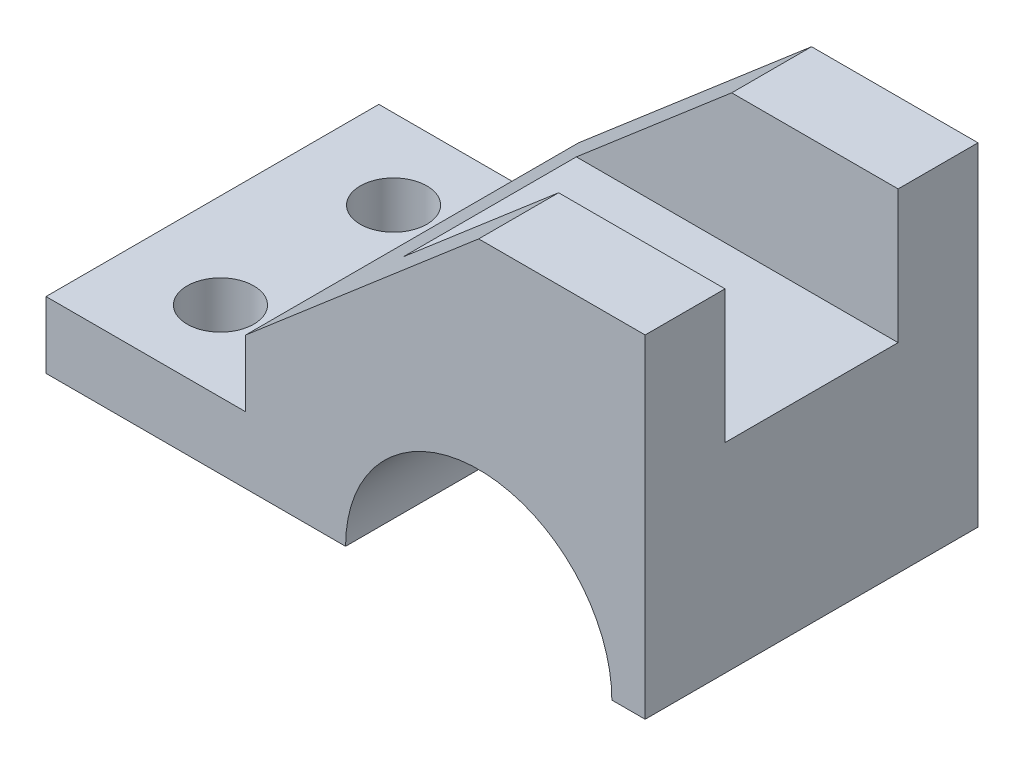
from build123d import *

# Parameters (mm, degrees)
SALIENTE_EXTRUIR2_DEPTH = 50
CROQUIS3_R              = 5
CORTAR_EXTRUIR3_DEPTH   = 10
CROQUIS5_W              = 26
CROQUIS5_H              = 20
CORTAR_EXTRUIR4_DEPTH   = 100


with BuildPart() as part:
    # Croquis1 → Saliente-Extruir2 (new body)
    with BuildSketch(Plane.XY):
        with BuildLine():
            Line((-68.920564692, -21.589574482), (-23.920564692, -21.589574482))
            ThreePointArc((-23.920564692, -21.589574482), (-3.920564692, -1.589574482), (16.079435308, -21.589574482))
            Line((16.079435308, -21.589574482), (21.079435308, -21.589574482))
            Line((21.079435308, -21.589574482), (21.079435308, 28.410425518))
            Line((21.079435308, 28.410425518), (-3.920564692, 28.410425518))
            Line((-3.920564692, 28.410425518), (-38.920564692, -1.589574482))
            Line((-38.920564692, -1.589574482), (-38.920564692, -11.589574482))
            Line((-38.920564692, -11.589574482), (-68.920564692, -11.589574482))
            Line((-68.920564692, -11.589574482), (-68.920564692, -21.589574482))
        make_face()
    extrude(amount=-SALIENTE_EXTRUIR2_DEPTH)

    # Croquis3 → Cortar-Extruir3 (cut)
    with BuildSketch(Plane(origin=(0, -11.589574482, 0), x_dir=(1, 0, 0), z_dir=(0, 1, 0))):
        with Locations((-54.712100966, 38)):
            Circle(CROQUIS3_R)
        with Locations((-54.712100966, 12)):
            Circle(CROQUIS3_R)
    extrude(amount=-CORTAR_EXTRUIR3_DEPTH, mode=Mode.SUBTRACT)

    # Croquis5 → Cortar-Extruir4 (cut)
    with BuildSketch(Plane(origin=(21.079435308, 0, 0), x_dir=(0, 0, -1), z_dir=(1, 0, 0))):
        with Locations((25, 18.410425518)):
            Rectangle(CROQUIS5_W, CROQUIS5_H)
    extrude(amount=-CORTAR_EXTRUIR4_DEPTH, mode=Mode.SUBTRACT)


solid = part.part
